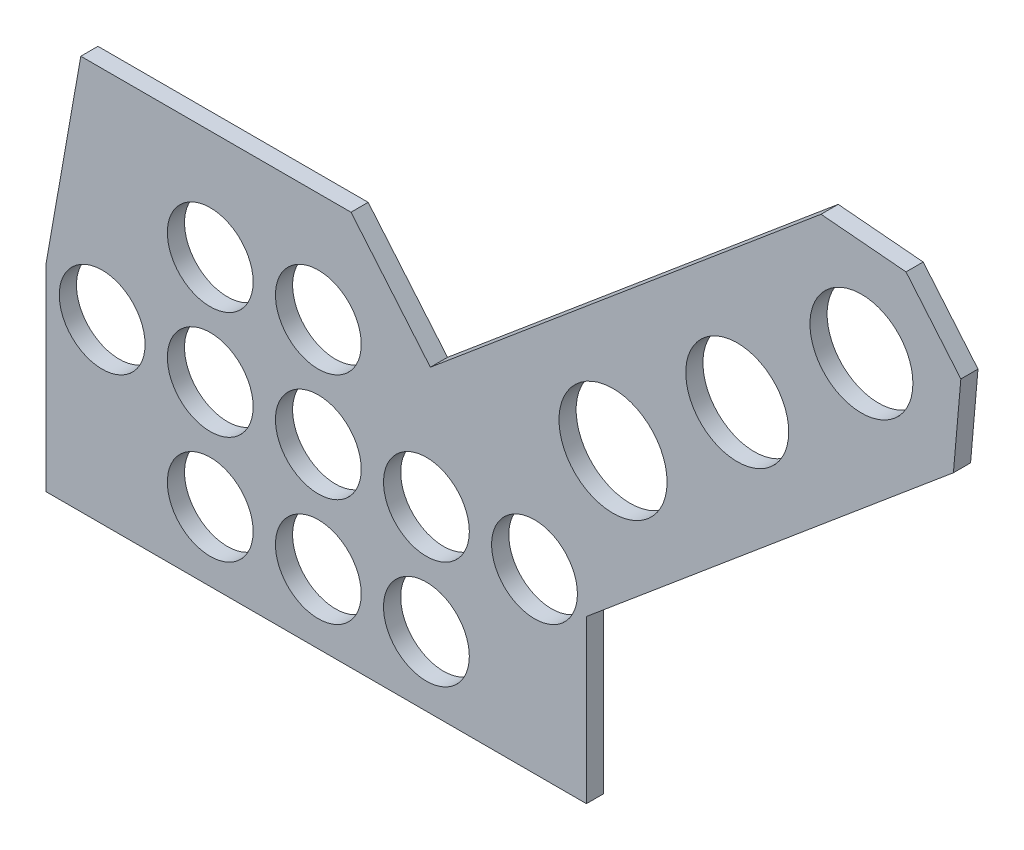
from build123d import *

# Parameters (mm, degrees)
BASE_EXTRUDE_DEPTH = 3.175
SKETCH3_R          = 9.525
SKETCH3_R_2        = 10
SKETCH3_R_3        = 7.9375
HOLES_DEPTH        = 4.175


with BuildPart() as part:
    # Sketch2 → Base Extrude (new body)
    with BuildSketch(Plane.XY):
        Polygon((0, 0), (100, 0), (100, 30), (167.901300028, 86.97595581), (169.276751583, 102.697439025), (159.132575314, 114.786797538), (143.411092099, 116.162249093), (71.118715891, 55.50174288), (56.435934796, 73), (6.435934796, 73), (0, 36.5), align=None)
    extrude(amount=BASE_EXTRUDE_DEPTH)

    # Sketch3 → Holes (cut, through all)
    with BuildSketch(Plane.XY.offset(3.175)):
        with Locations((150.882386677, 97.563400756)):
            Circle(SKETCH3_R)
        with Locations((127.901053383, 78.279772465)):
            Circle(SKETCH3_R)
        with Locations((104.91972009, 58.996144175)):
            Circle(SKETCH3_R_2)
        with Locations((30.39150811, 52.766671577)):
            Circle(SKETCH3_R_3)
        with Locations((50.39150811, 52.766671577)):
            Circle(SKETCH3_R_3)
        with Locations((10.39150811, 32.766671577)):
            Circle(SKETCH3_R_3)
        with Locations((30.39150811, 32.766671577)):
            Circle(SKETCH3_R_3)
        with Locations((50.39150811, 32.766671577)):
            Circle(SKETCH3_R_3)
        with Locations((70.39150811, 32.766671577)):
            Circle(SKETCH3_R_3)
        with Locations((30.39150811, 12.766671577)):
            Circle(SKETCH3_R_3)
        with Locations((50.39150811, 12.766671577)):
            Circle(SKETCH3_R_3)
        with Locations((70.39150811, 12.766671577)):
            Circle(SKETCH3_R_3)
        with Locations((90.39150811, 32.766671577)):
            Circle(SKETCH3_R_3)
    extrude(amount=-HOLES_DEPTH, mode=Mode.SUBTRACT)


solid = part.part
